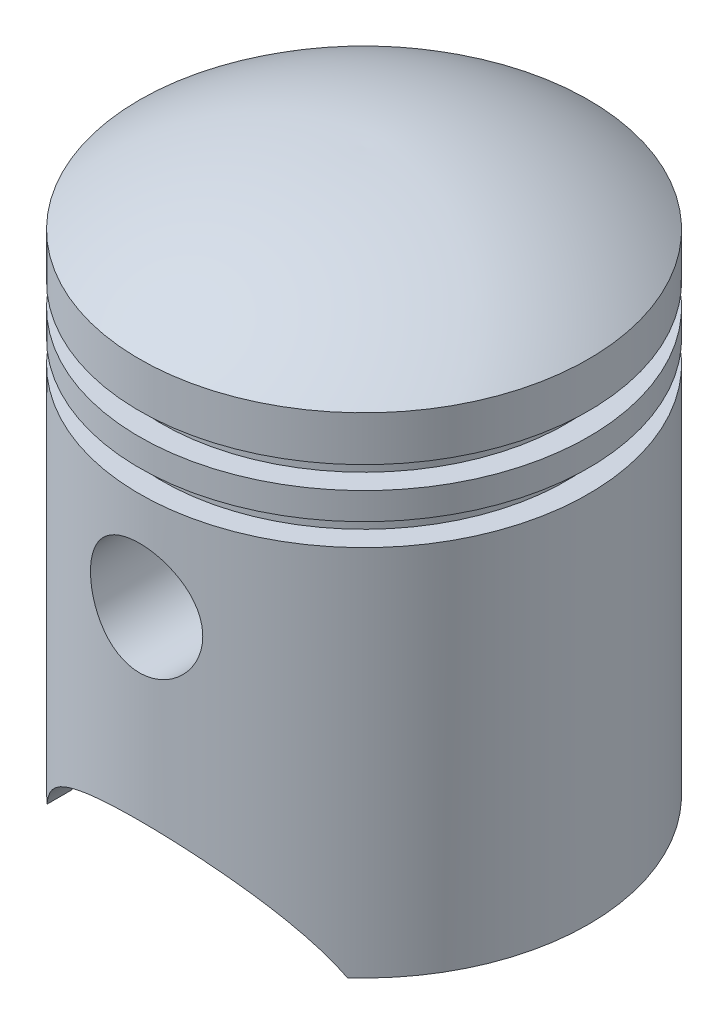
from build123d import *

# Parameters (mm, degrees)
SKETCH2_R               = 6.25
CUT_EXTRUDE1_DEPTH      = 26.0000001
CUT_EXTRUDE1_DEPTH_BACK = 26.0000001
BOSS_EXTRUDE4_START     = 12.5
SKETCH3_R               = 7.25
SKETCH3_R_2             = 6.25
BOSS_EXTRUDE4_DEPTH     = 11.425666


with BuildPart() as part:
    # Sketch1 → Revolve1 (revolve)
    with BuildSketch(Plane.XY):
        with BuildLine():
            Line((23, 0), (25, 0))
            Line((25, 0), (25, 41.5))
            Line((25, 41.5), (22.5, 41.5))
            Line((22.5, 41.5), (22.5, 44))
            Line((22.5, 44), (25, 44))
            Line((25, 44), (25, 47))
            Line((25, 47), (22.5, 47))
            Line((22.5, 47), (22.5, 49.5))
            Line((22.5, 49.5), (25, 49.5))
            Line((25, 49.5), (25, 54.5))
            ThreePointArc((25, 54.5), (13.174901691, 60.609067785), (0, 62.5))
            Line((0, 62.5), (0, 60.49936285))
            ThreePointArc((0, 60.49936285), (12.069492637, 58.859165445), (23, 53.484511145))
            Line((23, 53.484511145), (23, 51.5))
            Line((23, 51.5), (20.5, 51.5))
            Line((20.5, 51.5), (20.5, 39.5))
            Line((20.5, 39.5), (23, 39.5))
            Line((23, 39.5), (23, 0))
        make_face()
    revolve(axis=Axis((0, 62.5, 0), (0, -1, 0)))

    # Sketch2 → Cut-Extrude1 (cut, two sides)
    with BuildSketch(Plane.XY) as cut_extrude1_sk:
        with Locations((0, 30.5)):
            Circle(SKETCH2_R)
        with BuildLine():
            ThreePointArc((16.733200531, 0), (0, 10), (-16.733200531, 0))
            Line((-16.733200531, 0), (16.733200531, 0))
        make_face()
    extrude(amount=CUT_EXTRUDE1_DEPTH, mode=Mode.SUBTRACT)
    extrude(cut_extrude1_sk.sketch, amount=-CUT_EXTRUDE1_DEPTH_BACK, mode=Mode.SUBTRACT)

    # Sketch3 → Boss-Extrude4 (add)
    with BuildSketch(Plane.XY.offset(BOSS_EXTRUDE4_START)):
        with Locations((0, 30.5)):
            Circle(SKETCH3_R)
        with Locations((0, 30.5)):
            Circle(SKETCH3_R_2, mode=Mode.SUBTRACT)
    boss_extrude4 = extrude(amount=BOSS_EXTRUDE4_DEPTH)

    # Mirror1: Boss-Extrude4 across plane
    add(boss_extrude4.mirror(Plane.XY))


solid = part.part
